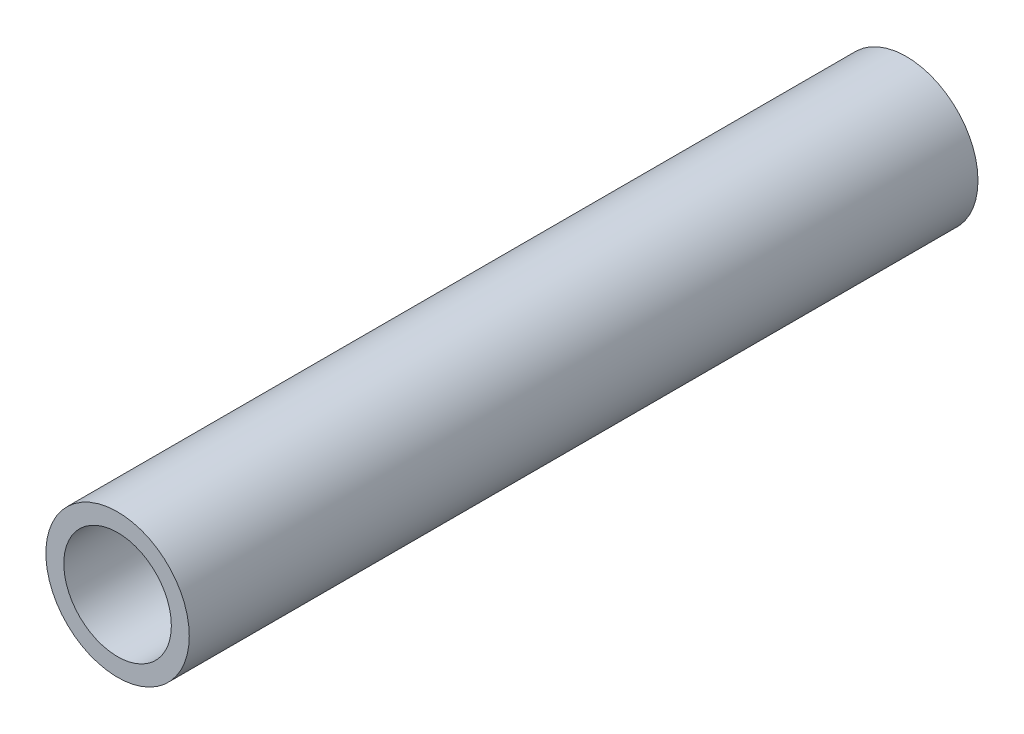
from build123d import *

# Parameters (mm, degrees)
SKETCH2_R           = 6.35
SKETCH2_R_2         = 4.7625
BOSS_EXTRUDE1_DEPTH = 34.925


with BuildPart() as part:
    # Sketch2 → Boss-Extrude1 (new body, symmetric)
    with BuildSketch(Plane(origin=(0, 0, 0), x_dir=(0, 1, 0), z_dir=(0, 0, 1))):
        Circle(SKETCH2_R)
        Circle(SKETCH2_R_2, mode=Mode.SUBTRACT)
    extrude(amount=BOSS_EXTRUDE1_DEPTH, both=True)


solid = part.part
